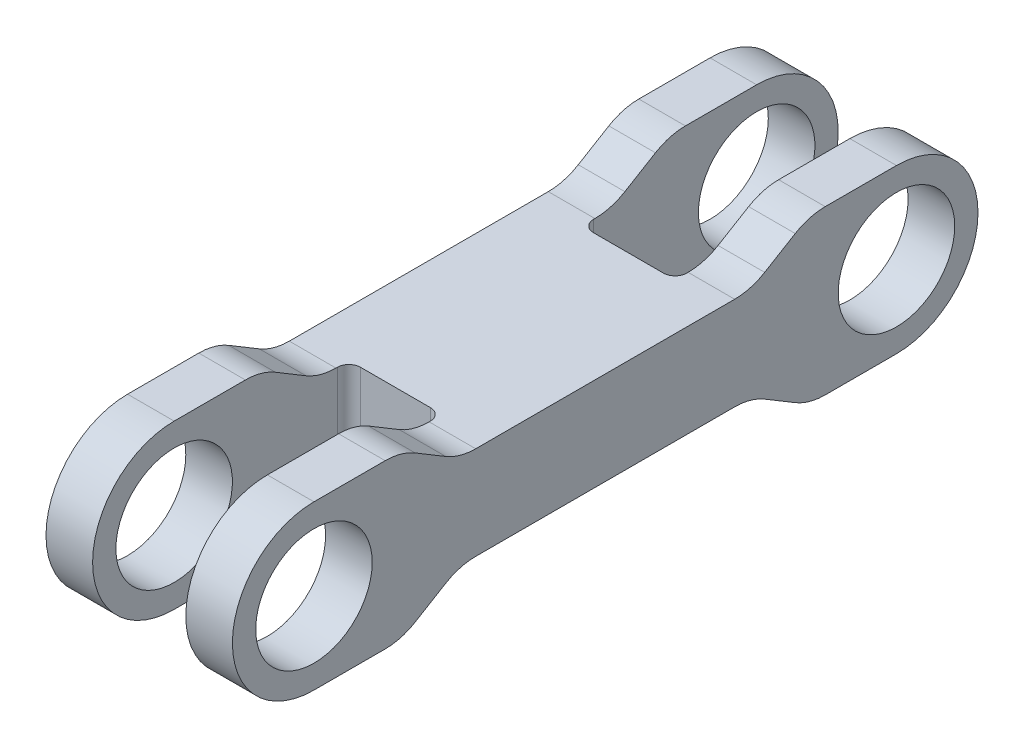
from build123d import *

# Parameters (mm, degrees)
SKETCH1_R               = 5
BOSS_EXTRUDE1_DEPTH     = 16
SKETCH2_W               = 8
SKETCH2_H               = 22
CUT_EXTRUDE1_DEPTH      = 8
CUT_EXTRUDE1_DEPTH_BACK = 8
FILLET1_R               = 1
CUT_EXTRUDE2_DEPTH      = 17
FILLET2_R               = 5


with BuildPart() as part:
    # Sketch1 → Boss-Extrude1 (new body)
    with BuildSketch(Plane(origin=(0, 0, 0), x_dir=(0, 0, -1), z_dir=(1, 0, 0))):
        with BuildLine():
            Line((0, 7), (50, 7))
            ThreePointArc((50, 7), (57, 0), (50, -7))
            Line((50, -7), (0, -7))
            ThreePointArc((0, -7), (-7, 0), (0, 7))
        make_face()
        Circle(SKETCH1_R, mode=Mode.SUBTRACT)
        with Locations((50, 0)):
            Circle(SKETCH1_R, mode=Mode.SUBTRACT)
    extrude(amount=BOSS_EXTRUDE1_DEPTH)

    # Sketch2 → Cut-Extrude1 (cut, two sides)
    with BuildSketch(Plane(origin=(0, 0, 0), x_dir=(1, 0, 0), z_dir=(0, 1, 0))) as cut_extrude1_sk:
        with Locations((8, 4)):
            Rectangle(SKETCH2_W, SKETCH2_H)
        with Locations((8, 46)):
            Rectangle(SKETCH2_W, SKETCH2_H)
    extrude(amount=CUT_EXTRUDE1_DEPTH, mode=Mode.SUBTRACT)
    extrude(cut_extrude1_sk.sketch, amount=-CUT_EXTRUDE1_DEPTH_BACK, mode=Mode.SUBTRACT)

    # Fillet1
    fillet1_edges = [part.edges().sort_by_distance(p)[0] for p in [
        (12, 0, -15),
        (4, 0, -15),
        (4, 0, -35),
        (12, 0, -35),
    ]]
    fillet(fillet1_edges, radius=FILLET1_R)

    # Sketch3 → Cut-Extrude2 (cut, through all)
    with BuildSketch(Plane(origin=(16, 0, 0), x_dir=(0, 0, -1), z_dir=(1, 0, 0))):
        with BuildLine():
            Line((13.884919825, -4), (36.115080175, -4))
            ThreePointArc((36.115080175, -4), (37.449748085, -4.181425359), (38.687558952, -4.712535371))
            Line((38.687558952, -4.712535371), (42.5, -7))
            Line((42.5, -7), (7.5, -7))
            Line((7.5, -7), (11.312441048, -4.712535371))
            ThreePointArc((11.312441048, -4.712535371), (12.550251915, -4.181425359), (13.884919825, -4))
        make_face()
        with BuildLine():
            Line((11.312441048, 4.712535371), (7.5, 7))
            Line((7.5, 7), (42.5, 7))
            Line((42.5, 7), (38.687558952, 4.712535371))
            ThreePointArc((38.687558952, 4.712535371), (37.449748085, 4.181425359), (36.115080175, 4))
            Line((36.115080175, 4), (13.884919825, 4))
            ThreePointArc((13.884919825, 4), (12.550251915, 4.181425359), (11.312441048, 4.712535371))
        make_face()
    extrude(amount=-CUT_EXTRUDE2_DEPTH, mode=Mode.SUBTRACT)

    # Fillet2
    fillet2_edges = [part.edges().sort_by_distance(p)[0] for p in [
        (2, -7, -7.5),
        (14, -7, -7.5),
        (14, -7, -42.5),
        (2, -7, -42.5),
        (2, 7, -42.5),
        (14, 7, -42.5),
        (2, 7, -7.5),
        (14, 7, -7.5),
    ]]
    fillet(fillet2_edges, radius=FILLET2_R)


solid = part.part
